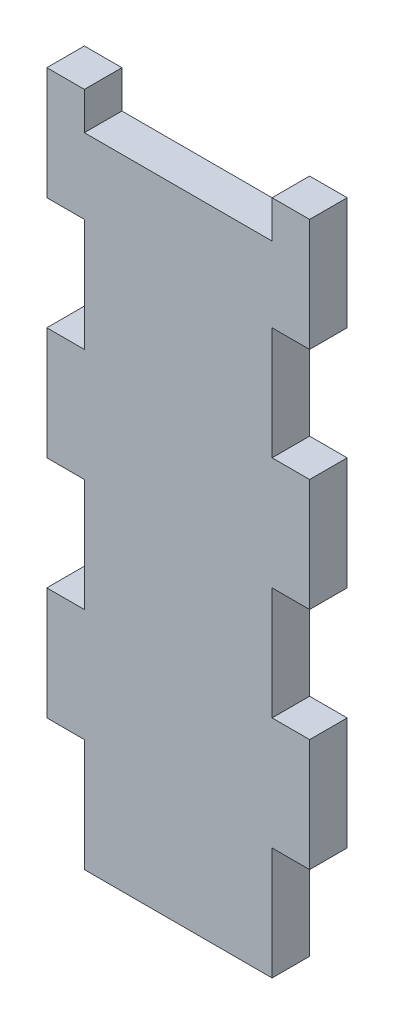
from build123d import *

# Parameters (mm, degrees)
BOSS_EXTRUDE1_DEPTH = 6


with BuildPart() as part:
    # Model → Boss-Extrude1 (new body)
    with BuildSketch(Plane.XY):
        Polygon((54.821544936, 115.324484296), (60.821544936, 115.324484296), (60.821544936, 97.324484296), (54.821544936, 97.324484296), (54.821544936, 79.324484296), (60.821544936, 79.324484296), (60.821544936, 61.324484296), (54.821544936, 61.324484296), (54.821544936, 43.324484296), (60.821544936, 43.324484296), (60.821544936, 25.324484296), (54.821544936, 25.324484296), (54.821544936, 7.324484296), (24.821544936, 7.324484296), (24.821544936, 15.324484296), (24.821544936, 25.324484296), (18.821544936, 25.324484296), (18.821544936, 43.324484296), (24.821544936, 43.324484296), (24.821544936, 61.324484296), (18.821544936, 61.324484296), (18.821544936, 79.324484296), (24.821544936, 79.324484296), (24.821544936, 97.324484296), (18.821544936, 97.324484296), (18.821544936, 115.324484296), (24.821544936, 115.324484296), (24.821544936, 109.324484296), (54.821544936, 109.324484296), align=None)
    extrude(amount=BOSS_EXTRUDE1_DEPTH)


solid = part.part
